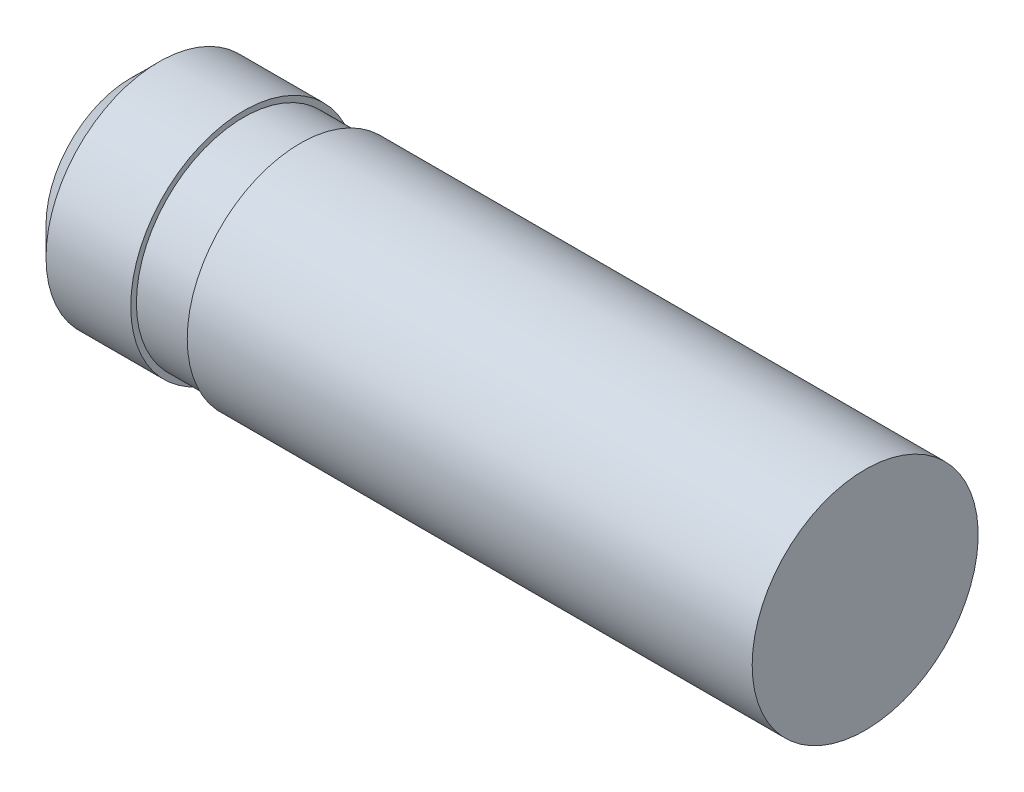
from build123d import *


with BuildPart() as part:
    # Эскиз1 → Повернуть1 (revolve)
    with BuildSketch(Plane.XY):
        Polygon((0, 0), (0, 1.5), (0.5, 2), (2, 2), (2, 1.9), (3, 1.9), (3, 2), (13, 2), (13, 0), align=None)
    revolve(axis=Axis((0, 0, 0), (1, 0, 0)))


solid = part.part
